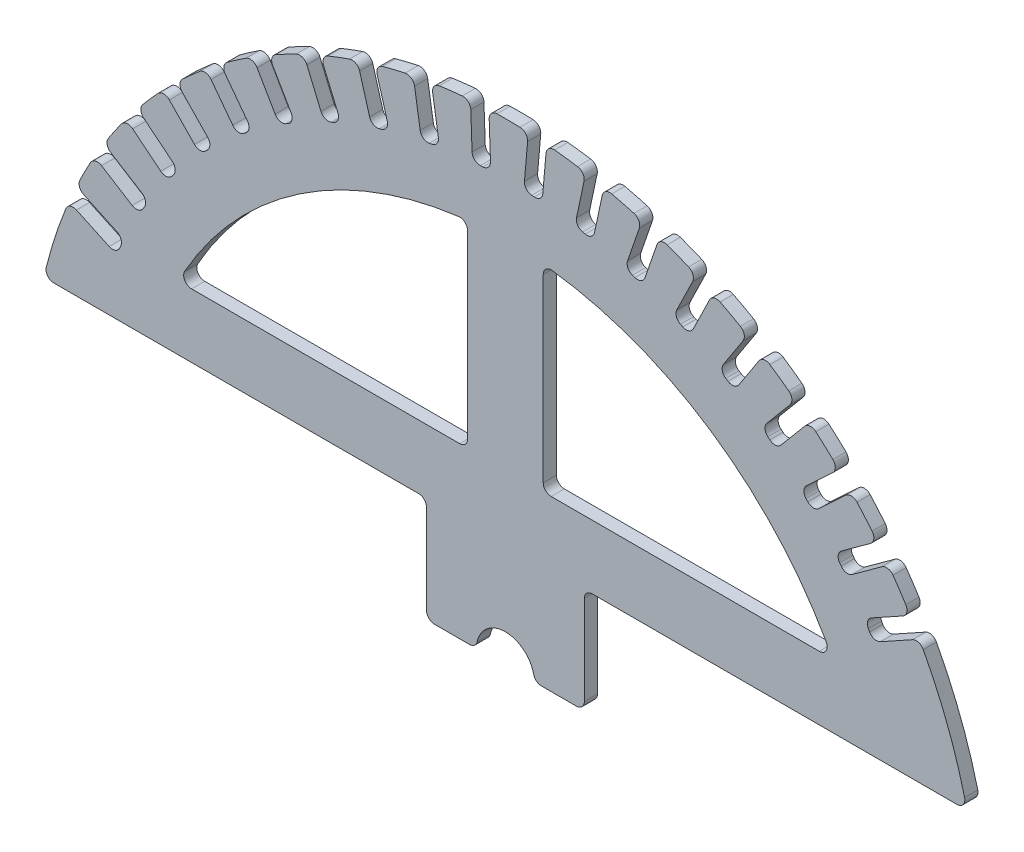
from build123d import *

# Parameters (mm, degrees)
BOSS_EXTRU_1_DEPTH                 = 5
ENL_V_MAT_EXTRU_2_DEPTH            = 6
CONG_1_R                           = 3
R_P_TITION_CIRCULAIRE1_COUNT       = 19
R_P_TITION_CIRCULAIRE1_ANGLE       = 126
CONG_1_OF_R_P_TITION_CIRCULAIRE1_R = 3
ENL_V_MAT_EXTRU_3_DEPTH            = 10
CONG_4_R                           = 3
CONG_4_OF_SYM_TRIE1_R              = 3
CONG_5_R                           = 3


with BuildPart() as part:
    # Esquisse1 → Boss.-Extru.1 (new body)
    with BuildSketch(Plane.XY):
        with BuildLine():
            Line((-11, 0), (-30, 0))
            Line((-30, 0), (-30, 40))
            Line((-30, 40), (-175.499287748, 40))
            ThreePointArc((-175.499287748, 40), (0, 180), (175.499287748, 40))
            Line((175.499287748, 40), (30, 40))
            Line((30, 40), (30, 0))
            Line((30, 0), (11, 0))
            ThreePointArc((11, 0), (0, 11), (-11, 0))
        make_face()
    extrude(amount=BOSS_EXTRU_1_DEPTH)

    # Esquisse3 → Enlèv. mat.-Extru.2 (cut, through all)
    with BuildSketch(Plane.XY.offset(5)):
        with BuildLine():
            Line((-163.135401667, 76.071287113), (-145.009245926, 67.618921879))
            Line((-145.009245926, 67.618921879), (-147.967573758, 61.274767369))
            Line((-147.967573758, 61.274767369), (-165.970324263, 69.669587798))
            ThreePointArc((-165.970324263, 69.669587798), (-164.594370288, 72.88881852), (-163.135401667, 76.071287113))
        make_face()
    enl_v_mat_extru_2 = extrude(amount=-ENL_V_MAT_EXTRU_2_DEPTH, mode=Mode.SUBTRACT)

    # Congé1
    cong_1_edges = [part.edges().sort_by_distance(p)[0] for p in [
        (-165.970324263, 69.669587798, 2.5),
        (-163.135401667, 76.071287113, 2.5),
        (-145.009245926, 67.618921879, 2.5),
        (-147.967573758, 61.274767369, 2.5),
    ]]
    fillet(cong_1_edges, radius=CONG_1_R)

    # Répétition circulaire1: Enlèv. mat.-Extru.2 ×19 about axis
    r_p_tition_circulaire1_axis = Axis((0, 0, 0), (0, 0, -1))
    for i in range(1, R_P_TITION_CIRCULAIRE1_COUNT):
        add(enl_v_mat_extru_2.rotate(r_p_tition_circulaire1_axis, i * R_P_TITION_CIRCULAIRE1_ANGLE / (R_P_TITION_CIRCULAIRE1_COUNT - 1)), mode=Mode.SUBTRACT)

    # Congé1 of Répétition circulaire1
    cong_1_of_r_p_tition_circulaire1_edges = [part.edges().sort_by_distance(p)[0] for p in [
        (-156.242619714, 89.376975698, 2.5),
        (-152.648657308, 95.385467562, 2.5),
        (-135.687695385, 84.787082277, 2.5),
        (-139.397130235, 78.850745604, 2.5),
        (-144.185697576, 107.751958751, 2.5),
        (-139.886273062, 113.277670389, 2.5),
        (-124.343353833, 100.691262568, 2.5),
        (-128.74859657, 95.251240838, 2.5),
        (-129.979298787, 124.520608282, 2.5),
        (-125.038506683, 129.481164061, 2.5),
        (-111.145339273, 115.094368054, 2.5),
        (-116.180717876, 110.231759461, 2.5),
        (-113.835208032, 139.43294235, 2.5),
        (-108.326704167, 143.754391809, 2.5),
        (-96.290403704, 127.781681608, 2.5),
        (-101.880852275, 123.568976446, 2.5),
        (-95.994096521, 152.2666524, 2.5),
        (-90, 155.884572681, 2.5),
        (-80, 138.564064606, 2.5),
        (-86.062177826, 135.064064606, 2.5),
        (-76.721934131, 162.830417377, 2.5),
        (-70.331603128, 165.690873621, 2.5),
        (-62.516980558, 147.280776552, 2.5),
        (-68.960514532, 144.545658653, 2.5),
        (-56.306024416, 170.966755875, 2.5),
        (-49.614724047, 173.027105269, 2.5),
        (-44.101976931, 153.80187135, 2.5),
        (-50.830808802, 151.872409859, 2.5),
        (-35.050721566, 176.554373828, 2.5),
        (-28.158203707, 177.783901307, 2.5),
        (-25.029514406, 158.030134495, 2.5),
        (-31.943332791, 156.93509324, 2.5),
        (-13.272893189, 179.509972721, 2.5),
        (-6.281909406, 179.890348863, 2.5),
        (-5.583919472, 159.902532323, 2.5),
        (-12.579655262, 159.658235846, 2.5),
        (8.702803454, 179.789491384, 2.5),
        (15.688033695, 179.315045657, 2.5),
        (13.94491884, 159.391151695, 2.5),
        (6.971555953, 160.001241894, 2.5),
        (30.548761343, 177.388762836, 2.5),
        (37.424104347, 176.066568132, 2.5),
        (33.265870531, 156.503616117, 2.5),
        (26.418837326, 157.958997953, 2.5),
        (51.939307563, 172.34357641, 2.5),
        (58.602267802, 170.193343608, 2.5),
        (52.090904713, 151.282972096, 2.5),
        (45.472274684, 153.561949177, 2.5),
        (72.555558338, 164.729144217, 2.5),
        (78.906806422, 161.782928334, 2.5),
        (70.139383486, 143.807047408, 2.5),
        (63.847825162, 146.875645435, 2.5),
        (92.090172854, 154.6589799, 2.5),
        (98.035026303, 150.96070223, 2.5),
        (87.142245602, 134.187290871, 2.5),
        (81.271551627, 137.999764116, 2.5),
        (110.251935002, 142.283206417, 2.5),
        (115.701769744, 137.887999761, 2.5),
        (102.84601755, 122.567110899, 2.5),
        (97.483706448, 127.066624167, 2.5),
        (126.770094741, 127.786318045, 2.5),
        (131.643666291, 122.759704811, 2.5),
        (117.016592259, 109.11973761, 2.5),
        (112.242603739, 114.239213521, 2.5),
        (141.398404354, 111.384429998, 2.5),
        (145.623058987, 105.801345413, 2.5),
        (129.4427191, 94.045640367, 2.5),
        (125.328222334, 99.708759327, 2.5),
        (153.91878944, 93.32205665, 2.5),
        (157.431547285, 87.265731644, 2.5),
        (139.939153142, 77.569539239, 2.5),
        (136.545485801, 83.691877189, 2.5),
    ]]
    fillet(cong_1_of_r_p_tition_circulaire1_edges, radius=CONG_1_OF_R_P_TITION_CIRCULAIRE1_R)

    # Esquisse4 → Enlèv. mat.-Extru.3 (cut)
    with BuildSketch(Plane(origin=(0, 0, 0), x_dir=(-1, 0, 0), z_dir=(0, 0, -1))):
        with BuildLine():
            Line((-124.381396705, 64.259381834), (-14.381396705, 64.259381834))
            Line((-14.381396705, 64.259381834), (-14.381396705, 139.259381834))
            ThreePointArc((-14.381396705, 139.259381834), (-78.86715545, 115.671827993), (-124.381396705, 64.259381834))
        make_face()
    enl_v_mat_extru_3 = extrude(amount=-ENL_V_MAT_EXTRU_3_DEPTH, mode=Mode.SUBTRACT)

    # Congé4
    cong_4_edges = [part.edges().sort_by_distance(p)[0] for p in [
        (124.381396705, 64.259381834, 2.5),
        (14.381396705, 139.259381834, 2.5),
        (14.381396705, 64.259381834, 2.5),
    ]]
    fillet(cong_4_edges, radius=CONG_4_R)

    # Symétrie1: Enlèv. mat.-Extru.3 across plane
    add(enl_v_mat_extru_3.mirror(Plane(origin=(0, 0, 0), x_dir=(0, 0, 1), z_dir=(1, 0, 0))), mode=Mode.SUBTRACT)

    # Congé4 of Symétrie1
    cong_4_of_sym_trie1_edges = [part.edges().sort_by_distance(p)[0] for p in [
        (-124.381396705, 64.259381834, 2.5),
        (-14.381396705, 139.259381834, 2.5),
        (-14.381396705, 64.259381834, 2.5),
    ]]
    fillet(cong_4_of_sym_trie1_edges, radius=CONG_4_OF_SYM_TRIE1_R)

    # Congé5
    cong_5_edges = [part.edges().sort_by_distance(p)[0] for p in [
        (-11, 0, 2.5),
        (-30, 0, 2.5),
        (-30, 40, 2.5),
        (-175.499287748, 40, 2.5),
        (175.499287748, 40, 2.5),
        (30, 40, 2.5),
        (30, 0, 2.5),
        (11, 0, 2.5),
    ]]
    fillet(cong_5_edges, radius=CONG_5_R)


solid = part.part
